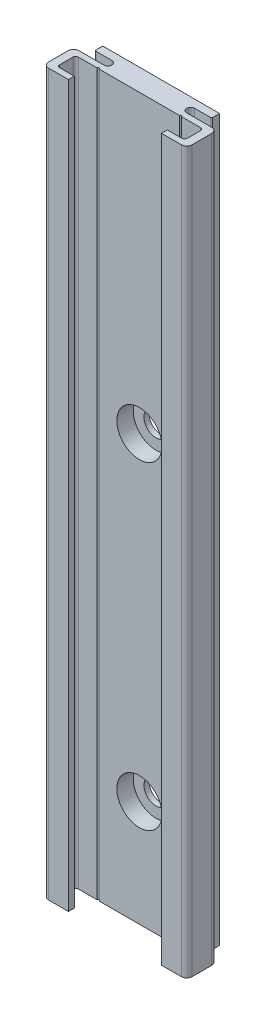
from build123d import *

# Parameters (mm, degrees)
BOSS_EXTRU_1_DEPTH                                 = 1000
ENL_V_MAT_EXTRU_1_DEPTH                            = 1001
CHAMBRAGE_POUR_VIS_T_TE_HEXAGONALE_M41_D           = 4.5
CHAMBRAGE_POUR_VIS_T_TE_HEXAGONALE_M41_DEPTH       = 4.1
CHAMBRAGE_POUR_VIS_T_TE_HEXAGONALE_M41_CBORE_D     = 8.5
CHAMBRAGE_POUR_VIS_T_TE_HEXAGONALE_M41_CBORE_DEPTH = 3.1
DIAM_TRE_DU_PER_AGE_0_4_0_4_1_D                    = 0.4
DIAM_TRE_DU_PER_AGE_0_4_0_4_1_DEPTH                = 1000
CONG_1_R                                           = 0.2
CONG_2_R                                           = 0.5
CONG_3_R                                           = 1
ESQUISSE9_W                                        = 27
ESQUISSE9_H                                        = 864.38
ENL_V_MAT_EXTRU_2_DEPTH                            = 9.7
ENL_V_MAT_EXTRU_2_DEPTH_BACK                       = 1


with BuildPart() as part:
    # Esquisse1 → Boss.-Extru.1 (new body)
    with BuildSketch(Plane.XZ):
        with BuildLine():
            Line((13.5, 8.7), (-13.5, 8.7))
            Line((-13.5, 8.7), (-13.5, 3))
            Line((-13.5, 3), (-7.8, 3))
            ThreePointArc((-7.8, 3), (-7.05, 2.25), (-7.8, 1.5))
            Line((-7.8, 1.5), (-11, 1.5))
            Line((-11, 1.5), (-11, 0))
            Line((-11, 0), (11, 0))
            Line((11, 0), (11, 1.5))
            Line((11, 1.5), (7.8, 1.5))
            ThreePointArc((7.8, 1.5), (7.05, 2.25), (7.8, 3))
            Line((7.8, 3), (13.5, 3))
            Line((13.5, 3), (13.5, 8.7))
        make_face()
    extrude(amount=-BOSS_EXTRU_1_DEPTH)

    # Esquisse2 → Enlèv. mat.-Extru.1 (cut, through all)
    with BuildSketch(Plane(origin=(0, 1000, 0), x_dir=(-1, 0, 0), z_dir=(0, 1, 0))):
        Polygon((8.75, 8.7), (-8.75, 8.7), (-8.75, 7.6), (-12, 7.6), (-12, 4.1), (12, 4.1), (12, 7.6), (8.75, 7.6), align=None)
    extrude(amount=-ENL_V_MAT_EXTRU_1_DEPTH, mode=Mode.SUBTRACT)

    # Chambrage pour vis à tête hexagonale M41
    with Locations(Plane.XY.offset(4.1)):
        with Locations((0, 980), (0, 920), (0, 860), (0, 800), (0, 740), (0, 680), (0, 620), (0, 560), (0, 500), (0, 440), (0, 380), (0, 320), (0, 260), (0, 200), (0, 140), (0, 80), (0, 20)):
            CounterBoreHole(CHAMBRAGE_POUR_VIS_T_TE_HEXAGONALE_M41_D / 2, CHAMBRAGE_POUR_VIS_T_TE_HEXAGONALE_M41_CBORE_D / 2, CHAMBRAGE_POUR_VIS_T_TE_HEXAGONALE_M41_CBORE_DEPTH, depth=CHAMBRAGE_POUR_VIS_T_TE_HEXAGONALE_M41_DEPTH)

    # Diamètre du perçage Ø0.4 (0.4)1
    with Locations(Plane(origin=(0, 0, 0), x_dir=(-1, 0, 0), z_dir=(0, -1, 0))):
        with Locations((7.75, -4.1), (-7.75, -4.1)):
            Hole(DIAM_TRE_DU_PER_AGE_0_4_0_4_1_D / 2, depth=DIAM_TRE_DU_PER_AGE_0_4_0_4_1_DEPTH)

    # Congé1
    cong_1_edges = [part.edges().sort_by_distance(p)[0] for p in [
        (11, 500, 1.5),
        (-11, 500, 1.5),
    ]]
    fillet(cong_1_edges, radius=CONG_1_R)

    # Congé2
    cong_2_edges = [part.edges().sort_by_distance(p)[0] for p in [
        (-12, 500, 7.6),
        (-12, 500, 4.1),
        (12, 500, 4.1),
        (12, 500, 7.6),
    ]]
    fillet(cong_2_edges, radius=CONG_2_R)

    # Congé3
    cong_3_edges = [part.edges().sort_by_distance(p)[0] for p in [
        (13.5, 500, 3),
        (-13.5, 500, 3),
        (-13.5, 500, 8.7),
        (13.5, 500, 8.7),
    ]]
    fillet(cong_3_edges, radius=CONG_3_R)

    # Esquisse9 → Enlèv. mat.-Extru.2 (cut, two sides)
    with BuildSketch(Plane.XY) as enl_v_mat_extru_2_sk:
        with Locations((0, 567.81)):
            Rectangle(ESQUISSE9_W, ESQUISSE9_H)
    extrude(amount=ENL_V_MAT_EXTRU_2_DEPTH, mode=Mode.SUBTRACT)
    extrude(enl_v_mat_extru_2_sk.sketch, amount=-ENL_V_MAT_EXTRU_2_DEPTH_BACK, mode=Mode.SUBTRACT)


solid = part.part
